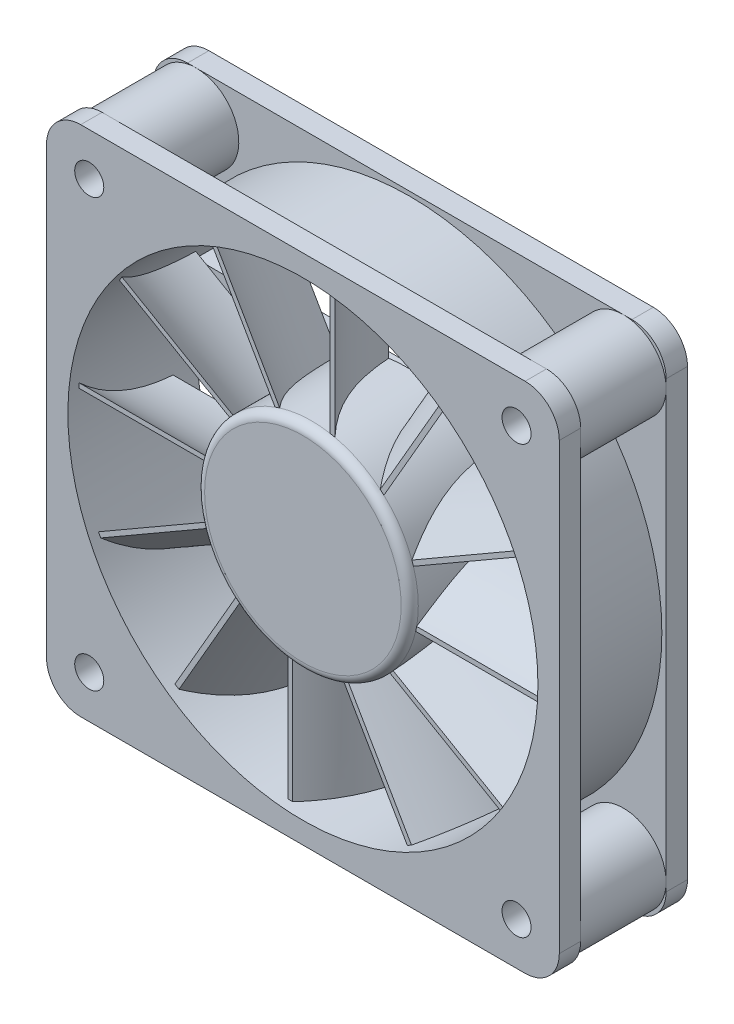
from build123d import *

# Parameters (mm, degrees)
SKETCH1_W                 = 60
SKETCH1_H                 = 60
SKETCH1_R                 = 27.5
SKETCH1_R_2               = 1.7
BOSS_EXTRUDE1_DEPTH       = 15
SKETCH2_W                 = 60
SKETCH2_H                 = 60
SKETCH2_R                 = 29.5
CUT_EXTRUDE1_DEPTH        = 5
CUT_EXTRUDE1_DEPTH_BACK   = 5
FILLET1_R                 = 4
SKETCH3_R                 = 5
SKETCH3_R_2               = 4
BOSS_EXTRUDE3_DEPTH       = 10
MIRROR2_COPY_1_SKETCH_R   = 5
MIRROR2_COPY_1_SKETCH_R_2 = 4
MIRROR2_COPY_1_DEPTH      = 10
BOSS_EXTRUDE4_DEPTH       = 2
BOSS_EXTRUDE5_START       = 1
SKETCH5_R                 = 12.5
BOSS_EXTRUDE5_DEPTH       = 12
FILLET2_R                 = 1
BOSS_EXTRUDE6_START       = 10
BOSS_EXTRUDE6_DEPTH       = 17.2
CUT_EXTRUDE2_DEPTH        = 12
CIRPATTERN1_COUNT         = 12


with BuildPart() as part:
    # Sketch1 → Boss-Extrude1 (new body)
    with BuildSketch(Plane.XY):
        with Locations((2.351816444, -5.277246654)):
            Rectangle(SKETCH1_W, SKETCH1_H)
        with Locations((2.351816444, -5.277246654)):
            Circle(SKETCH1_R, mode=Mode.SUBTRACT)
        with Locations((-22.648183556, 19.722753346)):
            Circle(SKETCH1_R_2, mode=Mode.SUBTRACT)
        with Locations((27.351816444, 19.722753346)):
            Circle(SKETCH1_R_2, mode=Mode.SUBTRACT)
        with Locations((27.351816444, -30.277246654)):
            Circle(SKETCH1_R_2, mode=Mode.SUBTRACT)
        with Locations((-22.648183556, -30.277246654)):
            Circle(SKETCH1_R_2, mode=Mode.SUBTRACT)
    extrude(amount=BOSS_EXTRUDE1_DEPTH)

    # Sketch2 → Cut-Extrude1 (cut, two sides)
    with BuildSketch(Plane.XY.offset(7.5)) as cut_extrude1_sk:
        with Locations((2.351816444, -5.277246654)):
            Rectangle(SKETCH2_W, SKETCH2_H)
        with Locations((2.351816444, -5.277246654)):
            Circle(SKETCH2_R, mode=Mode.SUBTRACT)
    extrude(amount=CUT_EXTRUDE1_DEPTH, mode=Mode.SUBTRACT)
    extrude(cut_extrude1_sk.sketch, amount=-CUT_EXTRUDE1_DEPTH_BACK, mode=Mode.SUBTRACT)

    # Fillet1
    fillet1_edges = [part.edges().sort_by_distance(p)[0] for p in [
        (-27.648183556, 24.722753346, 1.25),
        (32.351816444, 24.722753346, 1.25),
        (32.351816444, -35.277246654, 1.25),
        (-27.648183556, -35.277246654, 1.25),
        (-27.648183556, 24.722753346, 13.75),
        (32.351816444, 24.722753346, 13.75),
        (32.351816444, -35.277246654, 13.75),
        (-27.648183556, -35.277246654, 13.75),
    ]]
    fillet(fillet1_edges, radius=FILLET1_R)

    # Sketch3 → Boss-Extrude3 (add)
    with BuildSketch(Plane(origin=(0, 0, 12.5), x_dir=(-1, 0, 0), z_dir=(0, 0, -1))):
        with Locations((-27.351816444, 19.722753346)):
            Circle(SKETCH3_R)
        with Locations((-27.351816444, 19.722753346)):
            Circle(SKETCH3_R_2, mode=Mode.SUBTRACT)
    boss_extrude3 = extrude(amount=BOSS_EXTRUDE3_DEPTH)

    # Mirror1: Boss-Extrude3 across plane
    add(boss_extrude3.mirror(Plane(origin=(2.351816444, 0, 0), x_dir=(0, 0, 1), z_dir=(1, 0, 0))))

    # Mirror2: Boss-Extrude3 across plane
    add(boss_extrude3.mirror(Plane.ZX.offset(-5.277246654)))

    # Mirror2 copy 1 sketch → Mirror2 copy 1 (add)
    with BuildSketch(Plane(origin=(4.703632887, -10.554493308, 12.5), x_dir=(1, 0, 0), z_dir=(0, 0, -1))):
        with Locations((-27.351816444, 19.722753346)):
            Circle(MIRROR2_COPY_1_SKETCH_R)
        with Locations((-27.351816444, 19.722753346)):
            Circle(MIRROR2_COPY_1_SKETCH_R_2, mode=Mode.SUBTRACT)
    extrude(amount=MIRROR2_COPY_1_DEPTH)

    # Sketch4 → Boss-Extrude4 (add)
    with BuildSketch(Plane(origin=(0, 0, 0), x_dir=(-1, 0, 0), z_dir=(0, 0, -1))):
        with BuildLine():
            Line((23.192733417, 4.907348204), (-2.351816444, 4.722753346))
            ThreePointArc((-2.351816444, 4.722753346), (-5.684593789, 4.151040315), (-8.636292687, 2.501272379))
            Line((-8.636292687, 2.501272379), (-8.604641382, 21.502450512))
            ThreePointArc((-8.604641382, 21.502450512), (-10.593696666, 20.958633556), (-12.536411301, 20.267303207))
            Line((-12.536411301, 20.267303207), (-12.351816444, -5.277246654))
            ThreePointArc((-12.351816444, -5.277246654), (-11.780103412, -8.610024), (-10.130335476, -11.561722898))
            Line((-10.130335476, -11.561722898), (-29.131513609, -11.530071592))
            ThreePointArc((-29.131513609, -11.530071592), (-28.587696654, -13.519126876), (-27.896366304, -15.461841512))
            Line((-27.896366304, -15.461841512), (-2.351816444, -15.277246654))
            ThreePointArc((-2.351816444, -15.277246654), (0.980960902, -14.705533623), (3.9326598, -13.055765687))
            Line((3.9326598, -13.055765687), (3.9326598, -32.049533787))
            ThreePointArc((3.9326598, -32.049533787), (5.905568762, -31.508251011), (7.832778414, -30.821796515))
            Line((7.832778414, -30.821796515), (7.648183556, -5.277246654))
            ThreePointArc((7.648183556, -5.277246654), (7.076470525, -1.944469308), (5.426702589, 1.00722959))
            Line((5.426702589, 1.00722959), (24.42047069, 1.00722959))
            ThreePointArc((24.42047069, 1.00722959), (23.879187913, 2.980138552), (23.192733417, 4.907348204))
        make_face()
    extrude(amount=-BOSS_EXTRUDE4_DEPTH)


with BuildPart() as body_2:
    # Sketch5 → Boss-Extrude5 (new body)
    with BuildSketch(Plane.XY.offset(2).offset(BOSS_EXTRUDE5_START)):
        with Locations((2.351816444, -5.277246654)):
            Circle(SKETCH5_R)
    extrude(amount=BOSS_EXTRUDE5_DEPTH)

    # Fillet2
    fillet2_edges = [body_2.edges().sort_by_distance(p)[0] for p in [
        (-10.148183556, -5.277246654, 15),
    ]]
    fillet(fillet2_edges, radius=FILLET2_R)

    # Sketch6 → Boss-Extrude6 (add)
    with BuildSketch(Plane(origin=(0, -5.277246654, 0), x_dir=(1, 0, 0), z_dir=(0, 1, 0)).offset(BOSS_EXTRUDE6_START)):
        with BuildLine():
            Line((-0.150447431, -3), (0.386640035, -3))
            add(Edge.make_bspline(
                [(0.386640035, -3), (0.854849842, -9.428939059), (5.100029303, -14)],
                knots=[0, 0, 0, 1, 1, 1], degree=2))
            Line((5.100029303, -14), (4.541253192, -14))
            add(Edge.make_bspline(
                [(-0.150447431, -3), (0.32159222, -9.417919504), (4.541253192, -14)],
                knots=[0, 0, 0, 1, 1, 1], degree=2))
        make_face()
    boss_extrude6 = extrude(amount=BOSS_EXTRUDE6_DEPTH)

    # Sketch7 → Cut-Extrude2 (cut)
    with BuildSketch(Plane.XY.offset(15)):
        with BuildLine():
            Line((-0.150447431, 22.006814142), (-0.150447431, 21.760884905))
            ThreePointArc((-0.150447431, 21.760884905), (2.475369741, 21.876143877), (5.100029303, 21.736994198))
            Line((5.100029303, 21.736994198), (5.100029303, 21.983138965))
            ThreePointArc((5.100029303, 21.983138965), (2.475359369, 22.121038605), (-0.150447431, 22.006814142))
        make_face()
    extrude(amount=-CUT_EXTRUDE2_DEPTH, mode=Mode.SUBTRACT)

    # CirPattern1: Boss-Extrude6 ×12 about axis
    cirpattern1_axis = Axis((2.351816444, -5.277246654, 0), (0, 0, 1))
    for i in range(1, CIRPATTERN1_COUNT):
        add(boss_extrude6.rotate(cirpattern1_axis, i * 360 / CIRPATTERN1_COUNT))


solid = Compound([part.part, body_2.part])
